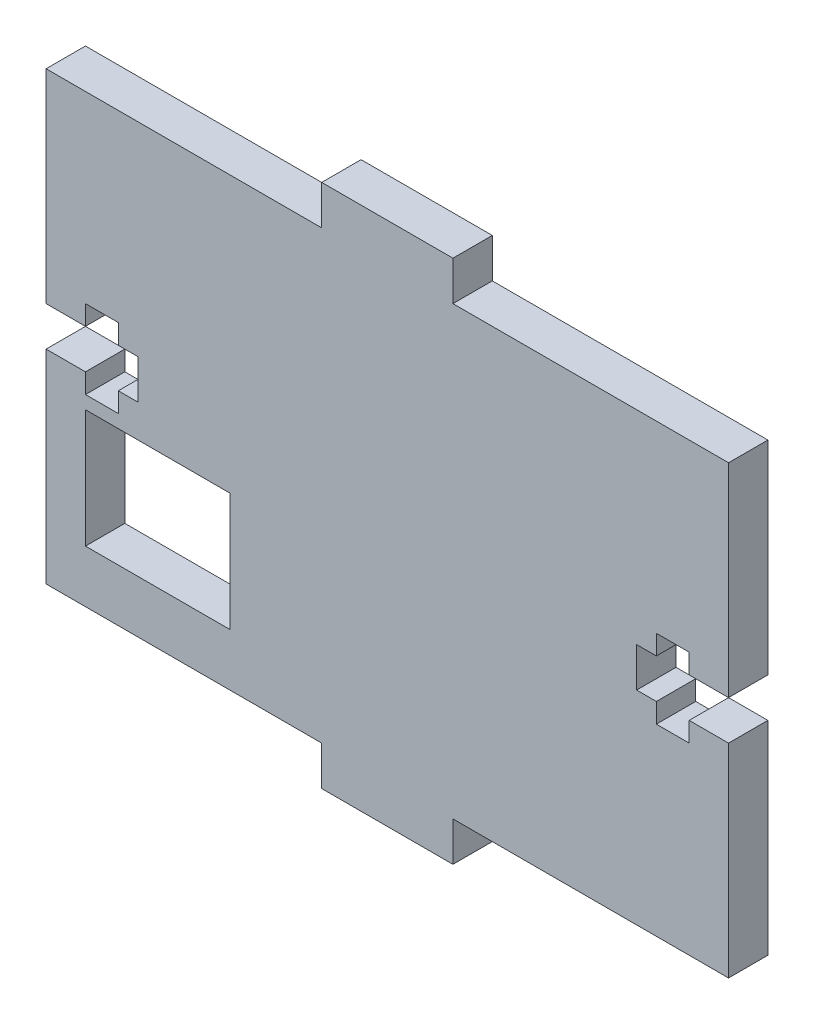
from build123d import *

# Parameters (mm, degrees)
SKETCH1_W           = 11
SKETCH1_H           = 9
BOSS_EXTRUDE1_DEPTH = 3


with BuildPart() as part:
    # Sketch1 → Boss-Extrude1 (new body)
    with BuildSketch(Plane.XY):
        Polygon((-26, -17), (-5, -17), (-5, -20), (5, -20), (5, -17), (26, -17), (26, -1.5), (23, -1.5), (23, -3), (20.5, -3), (20.5, -1.5), (19, -1.5), (19, 1.5), (20.5, 1.5), (20.5, 3), (23, 3), (23, 1.5), (26, 1.5), (26, 17), (5, 17), (5, 20), (-5, 20), (-5, 17), (-26, 17), (-26, 1.5), (-23, 1.5), (-23, 3), (-20.5, 3), (-20.5, 1.5), (-19, 1.5), (-19, -1.5), (-20.5, -1.5), (-20.5, -3), (-23, -3), (-23, -1.5), (-26, -1.5), align=None)
        with Locations((-17.5, -8.5)):
            Rectangle(SKETCH1_W, SKETCH1_H, mode=Mode.SUBTRACT)
    extrude(amount=BOSS_EXTRUDE1_DEPTH)


solid = part.part
